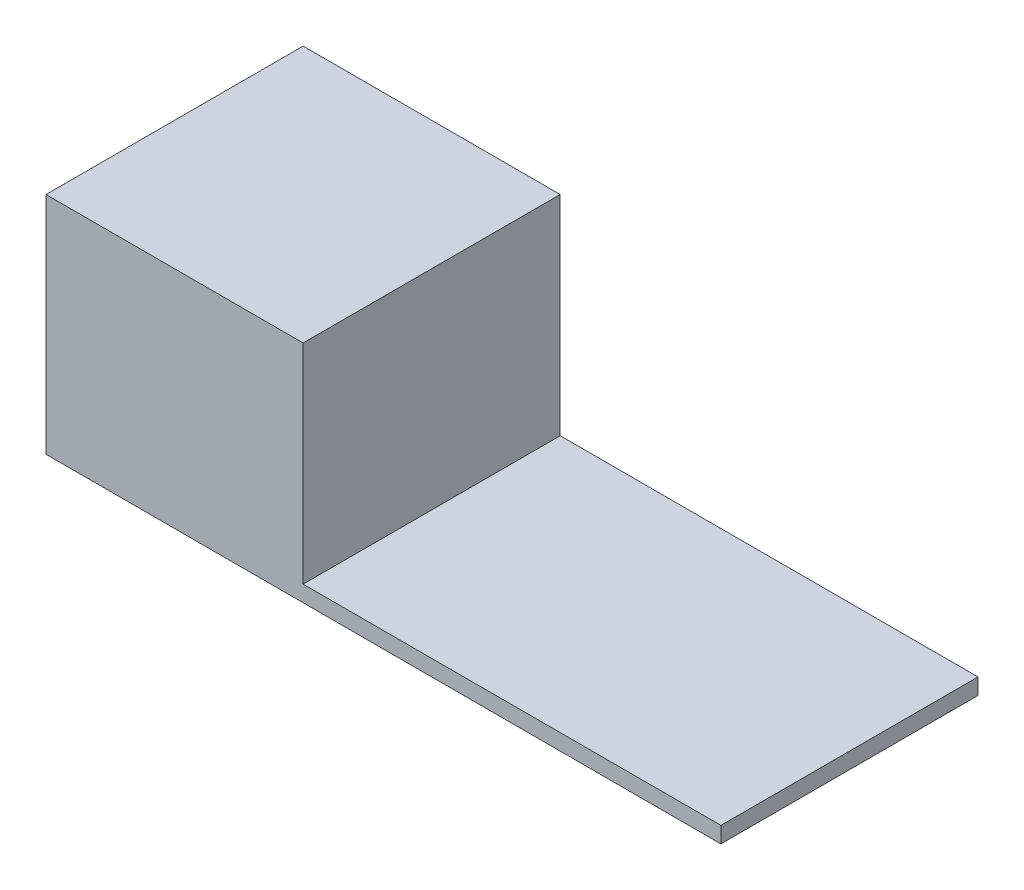
from build123d import *

# Parameters (mm, degrees)
SKETCH1_W           = 21
SKETCH1_H           = 8
BOSS_EXTRUDE1_DEPTH = 0.5
SKETCH2_W           = 8
SKETCH2_H           = 8
BOSS_EXTRUDE2_DEPTH = 6.5


with BuildPart() as part:
    # Sketch1 → Boss-Extrude1 (new body)
    with BuildSketch(Plane(origin=(0, 0, 0), x_dir=(1, 0, 0), z_dir=(0, 1, 0))):
        with Locations((-7.413293467, -1.856269018)):
            Rectangle(SKETCH1_W, SKETCH1_H)
    extrude(amount=BOSS_EXTRUDE1_DEPTH)

    # Sketch2 → Boss-Extrude2 (add)
    with BuildSketch(Plane(origin=(0, 0.5, 0), x_dir=(1, 0, 0), z_dir=(0, 1, 0))):
        with Locations((-13.913293467, -1.856269018)):
            Rectangle(SKETCH2_W, SKETCH2_H)
    extrude(amount=BOSS_EXTRUDE2_DEPTH)


solid = part.part
